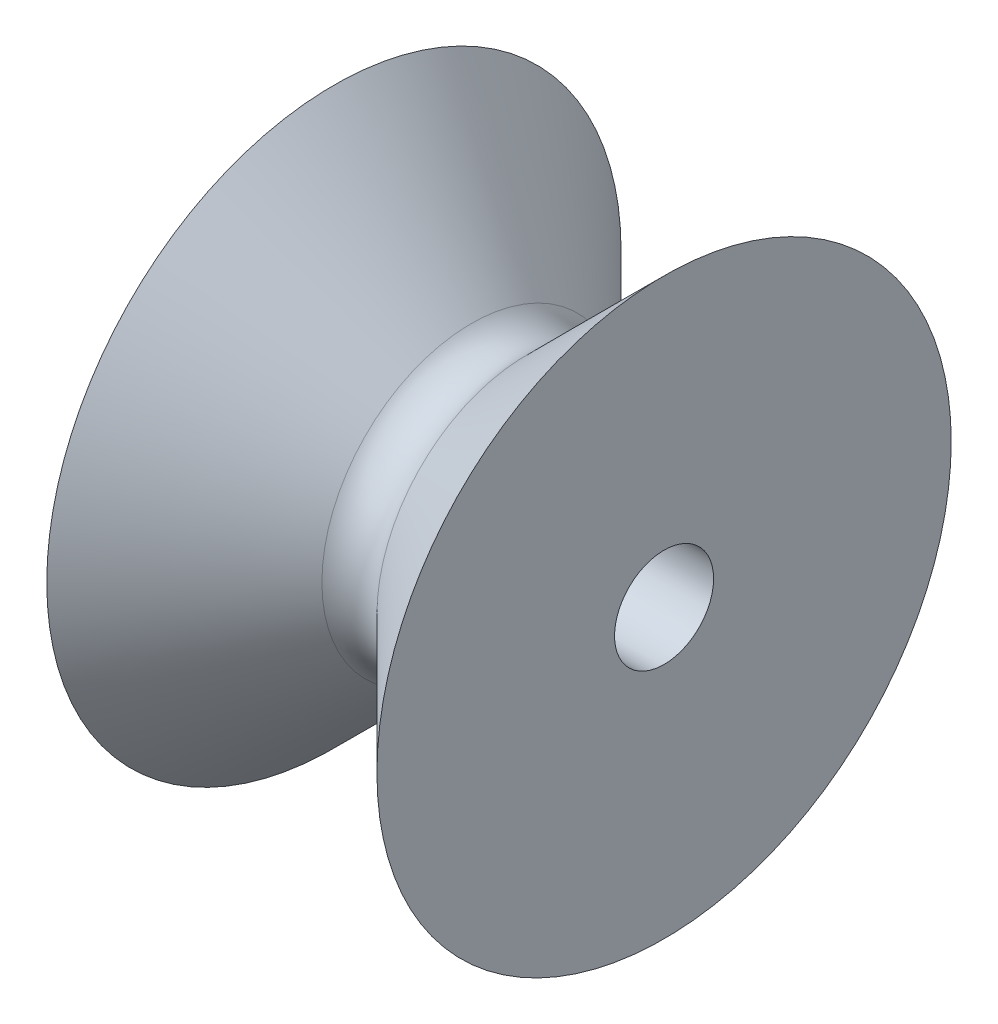
from build123d import *

# Parameters (mm, degrees)
SKETCH1_R           = 17.5
BOSS_EXTRUDE1_DEPTH = 18
SKETCH2_R           = 2.7
CUT_EXTRUDE1_DEPTH  = 18


with BuildPart() as part:
    # Sketch1 → Boss-Extrude1 (new body)
    with BuildSketch(Plane(origin=(0, 0, 0), x_dir=(0, 0, -1), z_dir=(1, 0, 0))):
        Circle(SKETCH1_R)
    extrude(amount=BOSS_EXTRUDE1_DEPTH)

    # Sketch2 → Cut-Extrude1 (cut)
    with BuildSketch(Plane(origin=(18, 0, 0), x_dir=(0, 0, -1), z_dir=(1, 0, 0))):
        Circle(SKETCH2_R)
    extrude(amount=-CUT_EXTRUDE1_DEPTH, mode=Mode.SUBTRACT)

    # Sketch3 → Cut-Revolve1 (revolve, cut)
    with BuildSketch(Plane.XY):
        with BuildLine():
            Line((10.5, 8.155563792), (24.900813008, 22.5563768))
            Line((24.900813008, 22.5563768), (-6.900813008, 22.5563768))
            Line((-6.900813008, 22.5563768), (7.5, 8.155563792))
            ThreePointArc((7.5, 8.155563792), (9, 7.534243448), (10.5, 8.155563792))
        make_face()
    revolve(axis=Axis((0, 0, 0), (1, 0, 0)), mode=Mode.SUBTRACT)


solid = part.part
